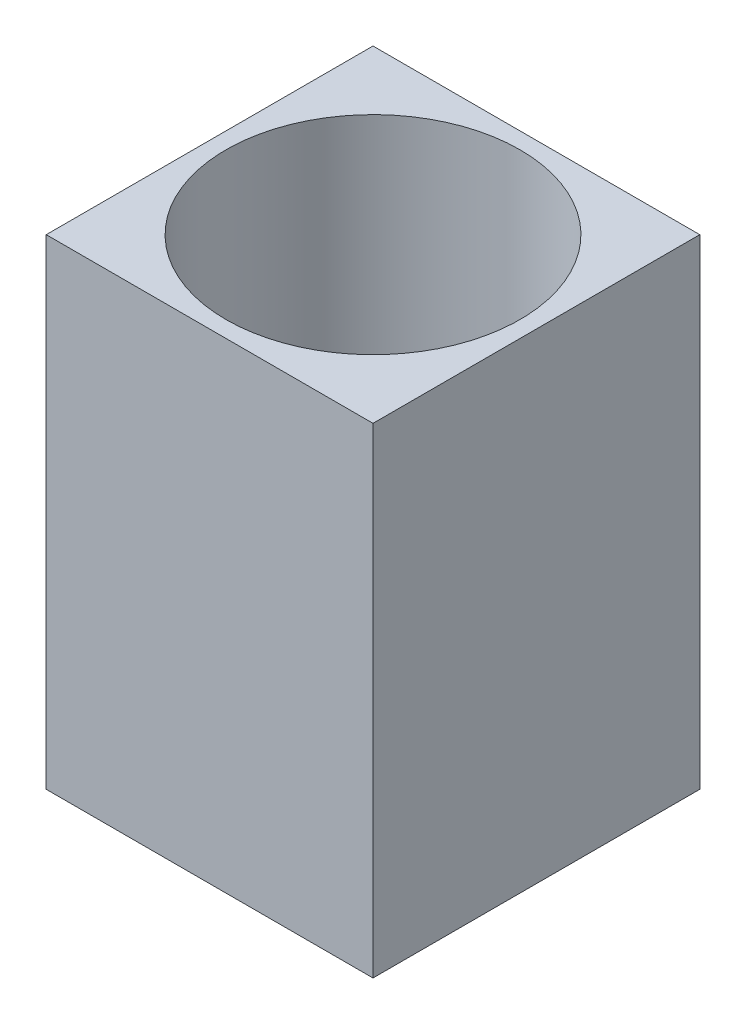
from build123d import *

# Parameters (mm, degrees)
SKETCH1_W           = 10
SKETCH1_H           = 10
SKETCH1_R           = 4.5
BOSS_EXTRUDE1_DEPTH = 14.7
SKETCH2_W           = 10
SKETCH2_H           = 10
SKETCH2_R           = 3.5
BOSS_EXTRUDE2_DEPTH = 3
SKETCH3_R           = 4.5
CUT_EXTRUDE1_DEPTH  = 2


with BuildPart() as part:
    # Sketch1 → Boss-Extrude1 (new body)
    with BuildSketch(Plane(origin=(0, 0, 0), x_dir=(1, 0, 0), z_dir=(0, 1, 0))):
        with Locations((5, -5)):
            Rectangle(SKETCH1_W, SKETCH1_H)
        with Locations((5, -5)):
            Circle(SKETCH1_R, mode=Mode.SUBTRACT)
    extrude(amount=BOSS_EXTRUDE1_DEPTH)

    # Sketch2 → Boss-Extrude2 (add)
    with BuildSketch(Plane(origin=(0, 0, 0), x_dir=(-1, 0, 0), z_dir=(0, -1, 0))):
        with Locations((-5, -5)):
            Rectangle(SKETCH2_W, SKETCH2_H)
        with Locations((-5, -5)):
            Circle(SKETCH2_R, mode=Mode.SUBTRACT)
    extrude(amount=-BOSS_EXTRUDE2_DEPTH)

    # Sketch3 → Cut-Extrude1 (cut)
    with BuildSketch(Plane(origin=(0, 0, 0), x_dir=(-1, 0, 0), z_dir=(0, -1, 0))):
        with Locations((-5, -5)):
            Circle(SKETCH3_R)
    extrude(amount=-CUT_EXTRUDE1_DEPTH, mode=Mode.SUBTRACT)


solid = part.part
